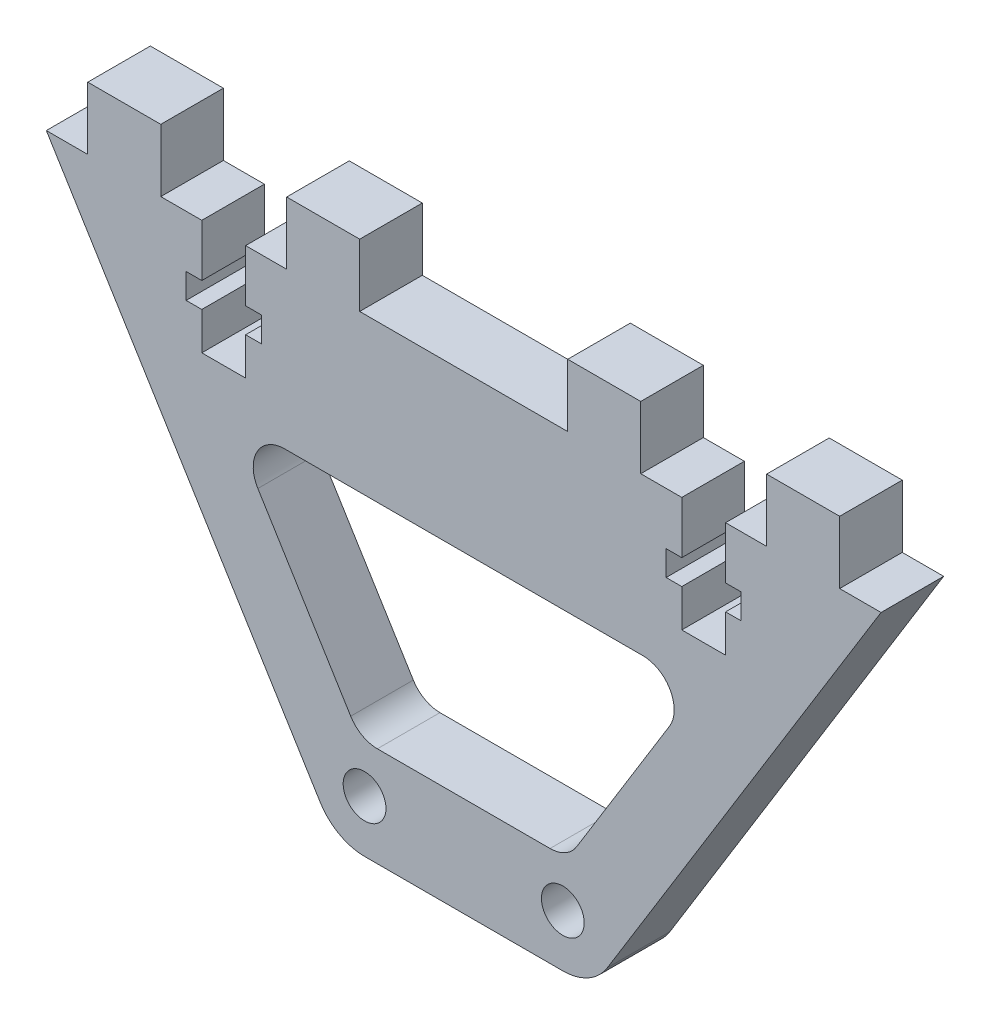
from build123d import *

# Parameters (mm, degrees)
SKETCH_1_R           = 2.05
EXTRUDE_1_DEPTH      = 6
SKETCH_2_W           = 7
SKETCH_2_H           = 6
EXTRUDE_2_DEPTH      = 6
CUT_EXTRUDE_1_DEPTH  = 7
SKETCH_21_W          = 7
SKETCH_21_H          = 6
EXTRUDE_21_DEPTH     = 6
SKETCH_22_W          = 7
SKETCH_22_H          = 6
EXTRUDE_22_DEPTH     = 6
CUT_EXTRUDE_12_DEPTH = 7


with BuildPart() as part:
    # Эскиз1 → Бобышка-Вытянуть1 (new body)
    with BuildSketch(Plane.XY):
        with BuildLine():
            Line((-40, 0), (40, 0))
            Line((40, 0), (13.757679871, -42.621480902))
            ThreePointArc((13.757679871, -42.621480902), (11.938503177, -44.365054668), (9.5, -45))
            Line((9.5, -45), (-9.5, -45))
            ThreePointArc((-9.5, -45), (-11.938503177, -44.365054668), (-13.757679871, -42.621480902))
            Line((-13.757679871, -42.621480902), (-40, 0))
        make_face()
        with Locations((-9.5, -40)):
            Circle(SKETCH_1_R, mode=Mode.SUBTRACT)
        with Locations((9.5, -40)):
            Circle(SKETCH_1_R, mode=Mode.SUBTRACT)
        with BuildLine():
            Line((-17.17379907, -15), (17.17379907, -15))
            ThreePointArc((17.17379907, -15), (19.792831871, -16.536898094), (19.728406993, -19.572888541))
            Line((19.728406993, -19.572888541), (10.829793891, -34.025576661))
            ThreePointArc((10.829793891, -34.025576661), (9.738287875, -35.071720921), (8.275185968, -35.45268812))
            Line((8.275185968, -35.45268812), (-8.275185968, -35.45268812))
            ThreePointArc((-8.275185968, -35.45268812), (-9.738287875, -35.071720921), (-10.829793891, -34.025576661))
            Line((-10.829793891, -34.025576661), (-19.728406993, -19.572888541))
            ThreePointArc((-19.728406993, -19.572888541), (-19.792831871, -16.536898094), (-17.17379907, -15))
        make_face(mode=Mode.SUBTRACT)
    extrude(amount=EXTRUDE_1_DEPTH)

    # Эскиз2 → Бобышка-Вытянуть2 (add)
    with BuildSketch(Plane(origin=(-23, -50, 0), x_dir=(-1, 0, 0), z_dir=(0, 0, -1))):
        with Locations((-9.531849908, 53)):
            Rectangle(SKETCH_2_W, SKETCH_2_H)
        with Locations((9.531849908, 53)):
            Rectangle(SKETCH_2_W, SKETCH_2_H)
    extrude(amount=-EXTRUDE_2_DEPTH)

    # Эскиз3 → Вырез-Вытянуть1 (cut, through all)
    with BuildSketch(Plane(origin=(-23, -50, 0), x_dir=(-1, 0, 0), z_dir=(0, 0, -1))):
        Polygon((-2.1, 45), (-3.6, 45), (-3.6, 42.6), (-2.1, 42.6), (-2.1, 39), (2.1, 39), (2.1, 42.6), (3.6, 42.6), (3.6, 45), (2.1, 45), (2.1, 50), (-2.1, 50), align=None)
    extrude(amount=-CUT_EXTRUDE_1_DEPTH, mode=Mode.SUBTRACT)

    # Эскиз21 → Бобышка-Вытянуть21 (add)
    with BuildSketch(Plane(origin=(-23, -50, 6), x_dir=(1, 0, 0), z_dir=(0, 0, 1))):
        with Locations((-9.531849908, 53)):
            Rectangle(SKETCH_21_W, SKETCH_21_H)
        with Locations((9.531849908, 53)):
            Rectangle(SKETCH_21_W, SKETCH_21_H)
    extrude(amount=-EXTRUDE_21_DEPTH)

    # Эскиз22 → Бобышка-Вытянуть22 (add)
    with BuildSketch(Plane(origin=(23, -50, 0), x_dir=(-1, 0, 0), z_dir=(0, 0, -1))):
        with Locations((-9.531849908, 53)):
            Rectangle(SKETCH_22_W, SKETCH_22_H)
        with Locations((9.531849908, 53)):
            Rectangle(SKETCH_22_W, SKETCH_22_H)
    extrude(amount=-EXTRUDE_22_DEPTH)

    # Эскиз32 → Вырез-Вытянуть12 (cut, through all)
    with BuildSketch(Plane(origin=(23, -50, 0), x_dir=(-1, 0, 0), z_dir=(0, 0, -1))):
        Polygon((-2.1, 45), (-3.6, 45), (-3.6, 42.6), (-2.1, 42.6), (-2.1, 39), (2.1, 39), (2.1, 42.6), (3.6, 42.6), (3.6, 45), (2.1, 45), (2.1, 50), (-2.1, 50), align=None)
    extrude(amount=-CUT_EXTRUDE_12_DEPTH, mode=Mode.SUBTRACT)


solid = part.part
